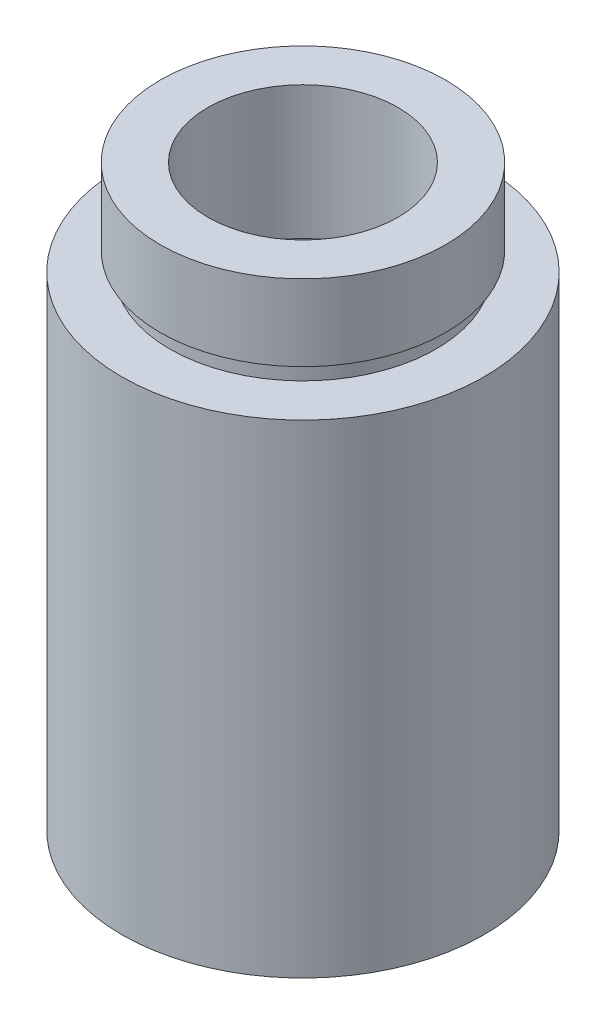
from build123d import *


with BuildPart() as part:
    # 草图1 → 旋转1 (revolve)
    with BuildSketch(Plane.XY, mode=Mode.PRIVATE) as revolve_1_sk:
        Polygon((7, 26.4), (7.5, 26.4), (7.5, 30.4), (5, 30.4), (5, 23.4), (6.85, 23.4), (6.85, 22.4), (6.75, 22.4), (6.75, 5.5), (7.6, 5.5), (7.6, 4.5), (7, 4.5), (7, 0), (9.525, 0), (9.525, 25.4), (7, 25.4), align=None)
    revolve(revolve_1_sk.sketch.rotate(Axis((0, 161.376166943, 0), (0, -1, 0)), 90), axis=Axis((0, 161.376166943, 0), (0, -1, 0)))  # turned: the seam where the file's is


solid = part.part
